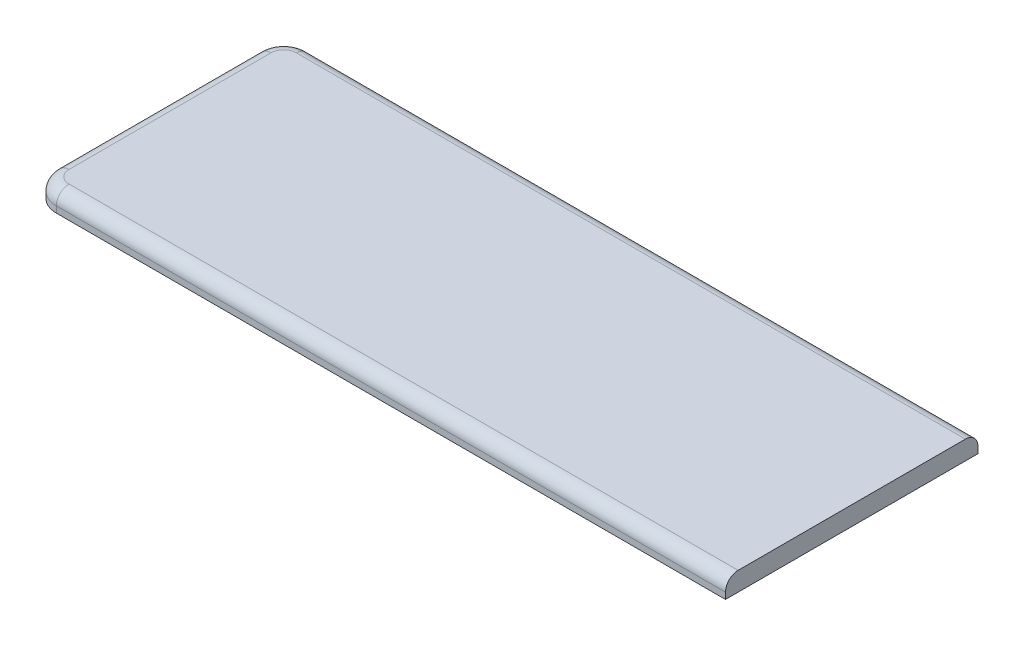
from build123d import *

# Parameters (mm, degrees)
SKETCH1_W           = 139.7
SKETCH1_H           = 50.8
BOSS_EXTRUDE1_DEPTH = 3.81
FILLET4_R           = 5.08
FILLET5_R           = 2.54


with BuildPart() as part:
    # Sketch1 → Boss-Extrude1 (new body)
    with BuildSketch(Plane(origin=(0, 0, 0), x_dir=(1, 0, 0), z_dir=(0, 1, 0))):
        Rectangle(SKETCH1_W, SKETCH1_H)
    extrude(amount=BOSS_EXTRUDE1_DEPTH)

    # Fillet4
    fillet4_edges = [part.edges().sort_by_distance(p)[0] for p in [
        (-69.85, 1.905, -25.4),
        (-69.85, 1.905, 25.4),
    ]]
    fillet(fillet4_edges, radius=FILLET4_R)

    # Fillet5
    fillet5_edges = [part.edges().sort_by_distance(p)[0] for p in [
        (-69.85, 3.81, 0),
        (2.54, 3.81, -25.4),
        (2.54, 3.81, 25.4),
        (-68.362102448, 3.81, 23.912102448),
        (-68.362102448, 3.81, -23.912102448),
    ]]
    fillet(fillet5_edges, radius=FILLET5_R)


solid = part.part
